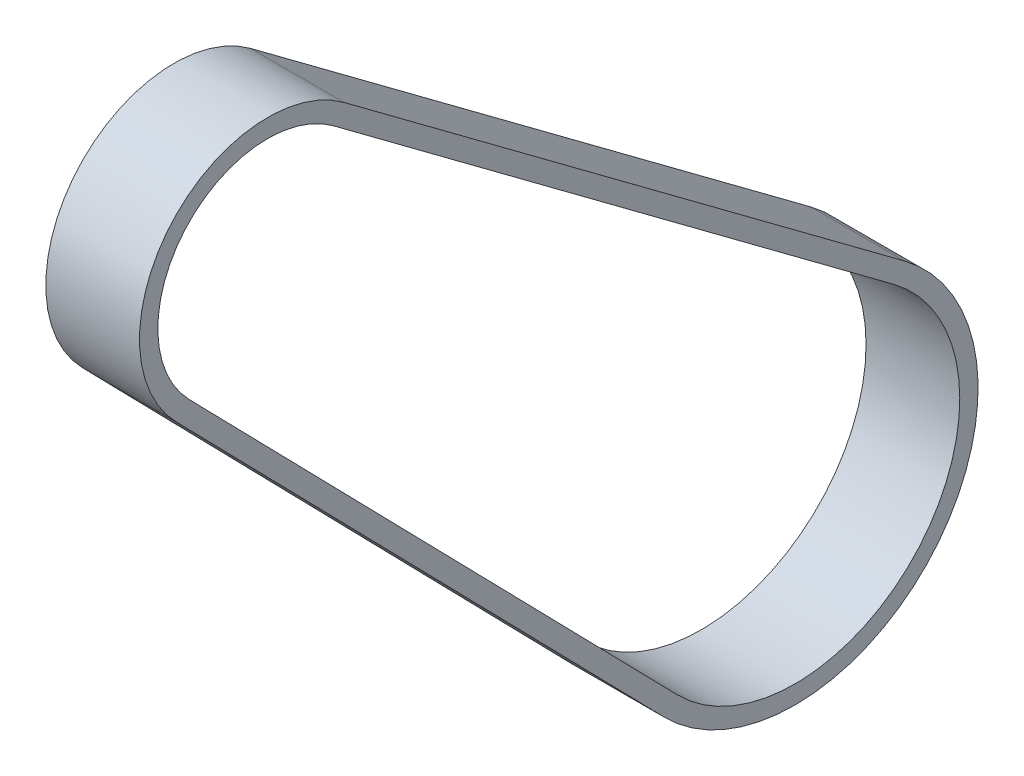
from build123d import *

# Parameters (mm, degrees)
BOSS_EXTRUDE1_DEPTH = 6.5


with BuildPart() as part:
    # Sketch1 → Boss-Extrude1 (new body)
    with BuildSketch(Plane(origin=(-63.134662924, 0, 0), x_dir=(0, 0, -1), z_dir=(1, 0, 0))):
        with BuildLine():
            Line((-10.565276343, -89.229749456), (-49.416189654, -60.285036457))
            ThreePointArc((-49.416189654, -60.285036457), (-61.41810481, -61.560228003), (-61.087779733, -73.625175837))
            Line((-61.087779733, -73.625175837), (-27.238976455, -108.287091427))
            ThreePointArc((-27.238976455, -108.287091427), (-8.594688607, -107.776631215), (-10.565276343, -89.229749456))
        make_face()
        with BuildLine():
            Line((-26.330356711, -107.399786428), (-60.179159989, -72.737870838))
            ThreePointArc((-60.179159989, -72.737870838), (-60.46229577, -62.39648698), (-50.174939921, -61.303465655))
            Line((-50.174939921, -61.303465655), (-46.502941226, -64.039178649))
            Line((-46.502941226, -64.039178649), (-11.32402661, -90.248178655))
            ThreePointArc((-11.32402661, -90.248178655), (-9.550497648, -106.940372237), (-26.330356711, -107.399786428))
        make_face(mode=Mode.SUBTRACT)
    extrude(amount=BOSS_EXTRUDE1_DEPTH)


solid = part.part
